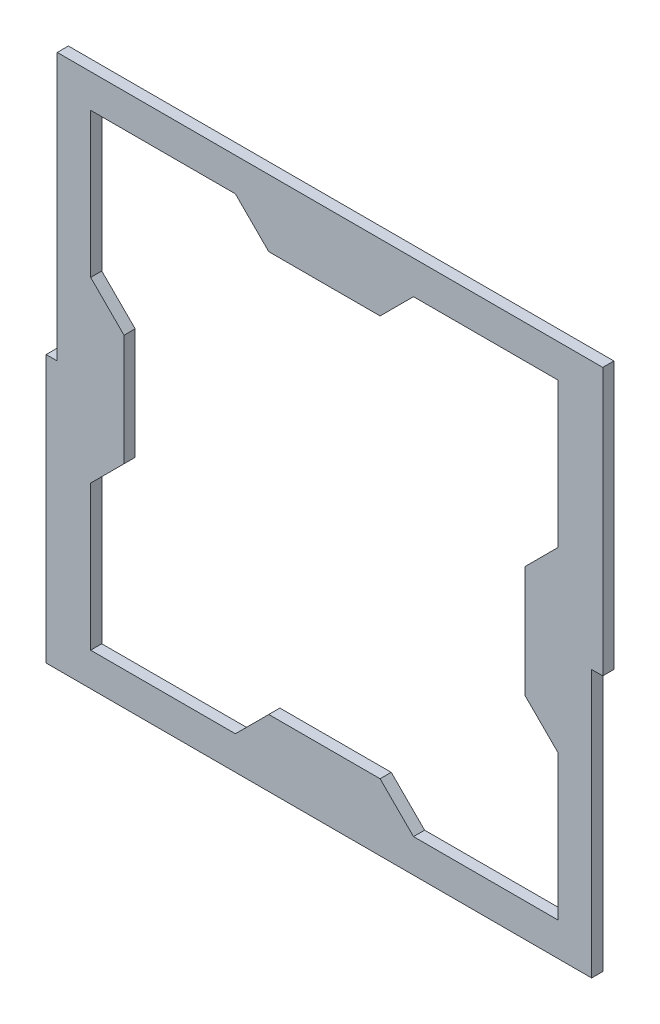
from build123d import *

# Parameters (mm, degrees)
SKETCH1_W           = 152.4
SKETCH1_H           = 152.4
SKETCH1_W_2         = 133.35
SKETCH1_H_2         = 133.35
BOSS_EXTRUDE1_DEPTH = 3.175
SKETCH2_W           = 3.175
SKETCH2_H           = 152.4
BOSS_EXTRUDE4_DEPTH = 3.175
SKETCH3_W           = 3.175
SKETCH3_H           = 76.2
BOSS_EXTRUDE5_DEPTH = 3.175
SKETCH4_W           = 3.175
SKETCH4_H           = 76.2
CUT_EXTRUDE1_DEPTH  = 3.175


with BuildPart() as part:
    # Sketch1 → Boss-Extrude1 (new body)
    with BuildSketch(Plane.XY):
        Rectangle(SKETCH1_W, SKETCH1_H)
        Rectangle(SKETCH1_W_2, SKETCH1_H_2, mode=Mode.SUBTRACT)
        Polygon((25.4, 66.675), (-25.4, 66.675), (-15.875, 57.15), (15.875, 57.15), align=None)
        Polygon((66.675, -25.4), (66.675, 25.4), (57.15, 15.875), (57.15, -15.875), align=None)
        Polygon((-15.875, -57.15), (-25.4, -66.675), (25.4, -66.675), (15.875, -57.15), align=None)
        Polygon((-57.15, 15.875), (-66.675, 25.4), (-66.675, -25.4), (-57.15, -15.875), align=None)
    extrude(amount=BOSS_EXTRUDE1_DEPTH)

    # Sketch2 → Boss-Extrude4 (add)
    with BuildSketch(Plane.XY.offset(3.175)):
        with Locations((77.7875, 0)):
            Rectangle(SKETCH2_W, SKETCH2_H)
    extrude(amount=-BOSS_EXTRUDE4_DEPTH)

    # Sketch3 → Boss-Extrude5 (add)
    with BuildSketch(Plane.XY.offset(3.175)):
        with Locations((77.7875, 38.1)):
            Rectangle(SKETCH3_W, SKETCH3_H)
        with Locations((-77.7875, -38.1)):
            Rectangle(SKETCH3_W, SKETCH3_H)
    extrude(amount=-BOSS_EXTRUDE5_DEPTH)

    # Sketch4 → Cut-Extrude1 (cut)
    with BuildSketch(Plane.XY.offset(3.175)):
        with Locations((77.7875, -38.1)):
            Rectangle(SKETCH4_W, SKETCH4_H)
    extrude(amount=-CUT_EXTRUDE1_DEPTH, mode=Mode.SUBTRACT)


solid = part.part
